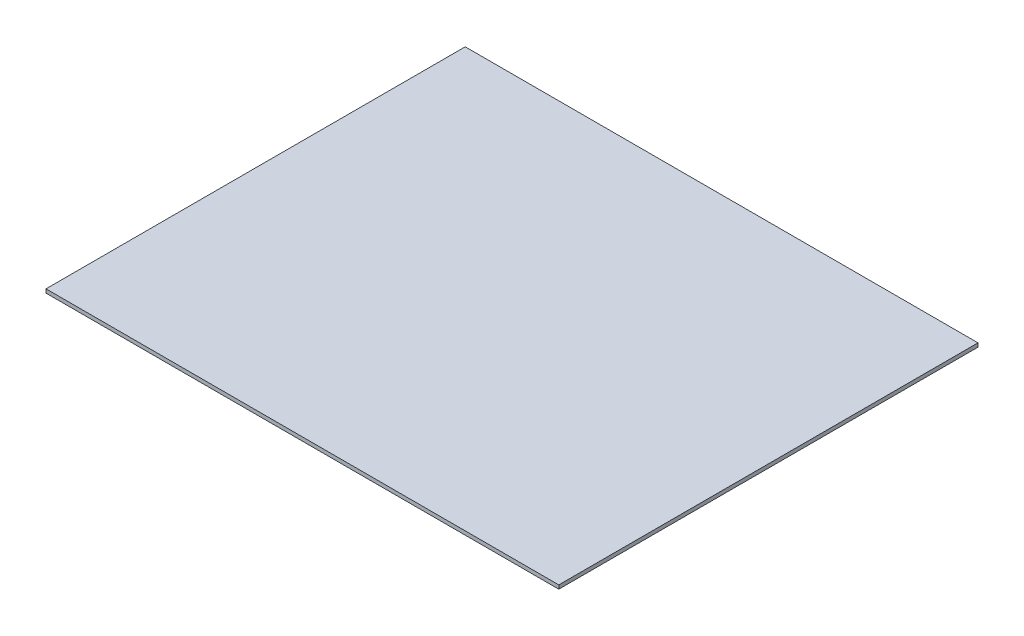
from build123d import *

# Parameters (mm, degrees)
SKETCH1_W           = 434.975
SKETCH1_H           = 355.6
BOSS_EXTRUDE1_DEPTH = 3.175


with BuildPart() as part:
    # Sketch1 → Boss-Extrude1 (new body)
    with BuildSketch(Plane(origin=(0, 0, 0), x_dir=(1, 0, 0), z_dir=(0, 1, 0))):
        Rectangle(SKETCH1_W, SKETCH1_H)
    extrude(amount=-BOSS_EXTRUDE1_DEPTH)


solid = part.part
